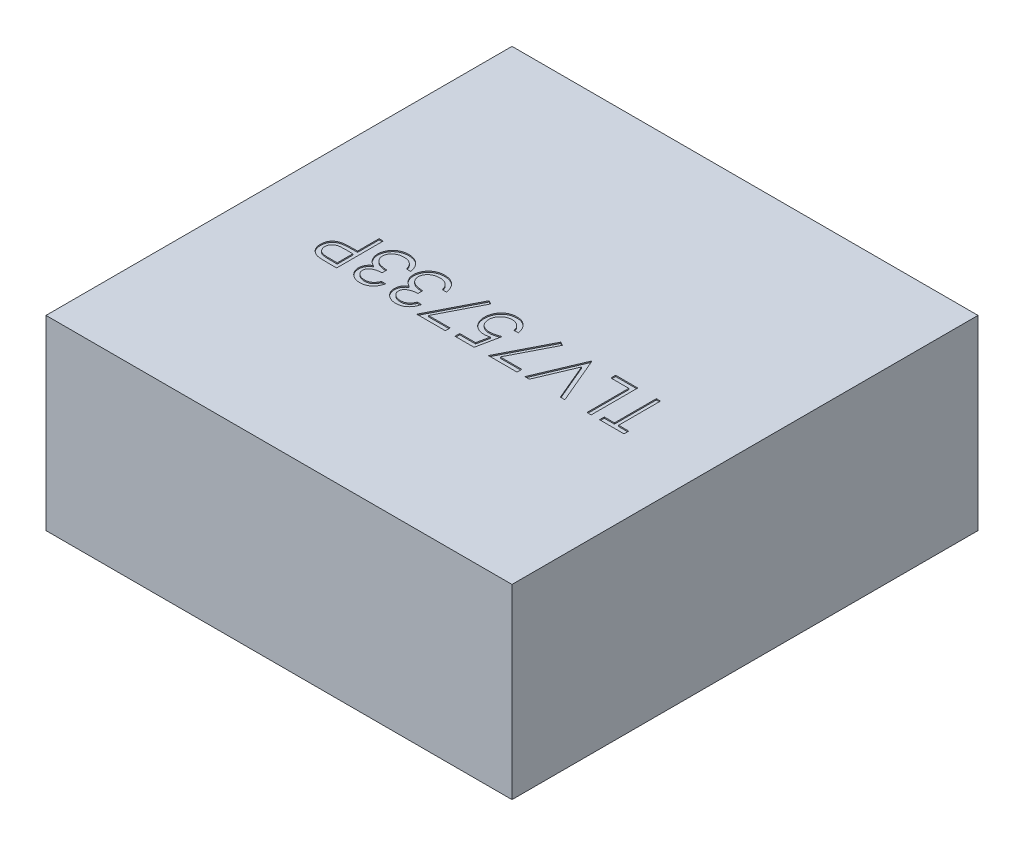
from build123d import *

# Parameters (mm, degrees)
BASES_W          = 2
BASES_H          = 2
BASE_DEPTH       = 0.8
PARTNUMBER_DEPTH = 0.005


with BuildPart() as part:
    # BaseS → Base (new body)
    with BuildSketch(Plane(origin=(0, 0, 0), x_dir=(1, 0, 0), z_dir=(0, 1, 0))):
        Rectangle(BASES_W, BASES_H)
    extrude(amount=BASE_DEPTH)

    # PartNumberS → PartNumber (cut)
    with BuildSketch(Plane(origin=(0, 0.8, 0), x_dir=(1, 0, 0), z_dir=(0, 1, 0))):
        Polygon((0.680769231, -0.179487179), (0.680769231, -0.2), (0.575641026, -0.2), (0.575641026, -0.179487179), (0.619230769, -0.179487179), (0.619230769, 0), (0.637179487, 0), (0.637179487, -0.179487179), align=None)
        Polygon((0.53974359, -0.2), (0.521794872, -0.2), (0.521794872, -0.020512821), (0.444871795, -0.020512821), (0.444871795, 0), (0.53974359, 0), align=None)
        Polygon((0.426923077, -0.2), (0.407692308, -0.2), (0.341025641, -0.042387821), (0.274358974, -0.2), (0.255128205, -0.2), (0.33974359, 0), (0.342307692, 0), align=None)
        Polygon((0.221794872, -0.2), (0.098717949, -0.2), (0.203846154, 0.005128205), (0.219350962, -0.003405449), (0.129086538, -0.179487179), (0.221794872, -0.179487179), align=None)
        with BuildLine():
            Line((-0.044871795, -0.2), (-0.044871795, -0.179487179))
            Line((-0.044871795, -0.179487179), (0.023157051, -0.179487179))
            Line((0.023157051, -0.179487179), (0.033934295, -0.126883013))
            add(Edge.make_bspline(
                [(0.033934295, -0.126883013), (0.031816816, -0.1274676), (0.027714537, -0.128600145), (0.021659687, -0.129857617), (0.015911561, -0.130615643), (0.01218154, -0.130719146), (0.010376603, -0.130769231)],
                knots=[0, 0, 0, 0, 1.100273476, 2.13160584, 3.095893838, 4, 4, 4, 4], degree=3))
            add(Edge.make_bspline(
                [(0.010376603, -0.130769231), (0.008142844, -0.130722475), (0.003750716, -0.130630542), (-0.00266564, -0.129695799), (-0.00882109, -0.128340984), (-0.014627096, -0.126257022), (-0.020177264, -0.12369573), (-0.025396346, -0.120511598), (-0.030308859, -0.116749998), (-0.034904064, -0.112488094), (-0.039046803, -0.107742932), (-0.04266112, -0.102636713), (-0.045750495, -0.097226416), (-0.048214901, -0.091462275), (-0.050212995, -0.085398611), (-0.051534137, -0.078984544), (-0.052415598, -0.072273437), (-0.05251395, -0.067684575), (-0.052564103, -0.065344551)],
                knots=[0, 0, 0, 0, 1.052656913, 2.069786496, 3.052102726, 4.020122636, 4.972424848, 5.930457368, 6.896570172, 7.885826804, 8.881139003, 9.861434336, 10.831623367, 11.813212553, 12.812997731, 13.836986694, 14.897002833, 16, 16, 16, 16], degree=3))
            add(Edge.make_bspline(
                [(-0.052564103, -0.065344551), (-0.052526069, -0.063714718), (-0.052450516, -0.060477078), (-0.052067024, -0.05566872), (-0.051326252, -0.050962711), (-0.050342361, -0.046368373), (-0.049034062, -0.041878849), (-0.047486935, -0.037483546), (-0.045635127, -0.033189737), (-0.043521961, -0.029018787), (-0.041117733, -0.02505279), (-0.038551881, -0.021245534), (-0.035755993, -0.017707472), (-0.032779013, -0.014379465), (-0.029563779, -0.011357231), (-0.026189195, -0.008514697), (-0.022579797, -0.005972433), (-0.018799216, -0.00363428), (-0.014850105, -0.001540748), (-0.010692348, 0.000205622), (-0.006417238, 0.001736333), (-0.001986665, 0.002981114), (0.002590784, 0.003946885), (0.007330874, 0.004604561), (0.01220982, 0.005083078), (0.015516956, 0.00511306), (0.0171875, 0.005128205)],
                knots=[0, 0, 0, 0, 1.056281413, 2.098288097, 3.122646807, 4.141030392, 5.140675379, 6.150604744, 7.15845591, 8.168533554, 9.177684096, 10.161739049, 11.141561652, 12.097360316, 13.052218386, 13.998410789, 14.954052752, 15.909851415, 16.877523809, 17.846742625, 18.829312613, 19.818263486, 20.826374662, 21.858017533, 22.918014209, 24, 24, 24, 24], degree=3))
            add(Edge.make_bspline(
                [(0.0171875, 0.005128205), (0.019180257, 0.005088619), (0.023100771, 0.005010738), (0.028845563, 0.004199816), (0.034369338, 0.003030456), (0.039649185, 0.001298915), (0.044660275, -0.000971722), (0.049475299, -0.003652227), (0.054006118, -0.006887491), (0.058284876, -0.010561531), (0.062209915, -0.014636501), (0.065823355, -0.018968808), (0.068952141, -0.023654541), (0.071670748, -0.028615525), (0.073983404, -0.033864696), (0.075801821, -0.039414236), (0.077269041, -0.045237188), (0.077889824, -0.049245947), (0.078205128, -0.051282051)],
                knots=[0, 0, 0, 0, 1.04695683, 2.059763882, 3.044413726, 4.012427942, 4.974081556, 5.932886124, 6.904940154, 7.895678616, 8.893654631, 9.876199664, 10.857615262, 11.850515636, 12.847107701, 13.868396357, 14.917328757, 16, 16, 16, 16], degree=3))
            Line((0.078205128, -0.051282051), (0.06025641, -0.051282051))
            add(Edge.make_bspline(
                [(0.06025641, -0.051282051), (0.059815333, -0.049374443), (0.058967558, -0.045707913), (0.057096993, -0.040562644), (0.054846086, -0.03595852), (0.052045418, -0.031924495), (0.04886416, -0.028324783), (0.045192472, -0.025123656), (0.041061558, -0.022270508), (0.036470494, -0.019872837), (0.031614568, -0.017856105), (0.026561981, -0.016416181), (0.021384479, -0.015544733), (0.017898621, -0.015438189), (0.016145833, -0.015384615)],
                knots=[0, 0, 0, 0, 1.136370375, 2.184166959, 3.172867797, 4.104539607, 5.027679118, 5.956634301, 6.927059835, 7.936867459, 8.959641981, 9.976160943, 10.98235693, 12, 12, 12, 12], degree=3))
            add(Edge.make_bspline(
                [(0.016145833, -0.015384615), (0.014434067, -0.015431909), (0.011063586, -0.015525032), (0.006100853, -0.016230204), (0.001323524, -0.017344777), (-0.00327688, -0.01890623), (-0.007677755, -0.02097194), (-0.011872877, -0.023509547), (-0.01592201, -0.026455739), (-0.019718587, -0.029823128), (-0.023194943, -0.033536101), (-0.026266769, -0.037506128), (-0.028825438, -0.041741405), (-0.030981676, -0.046168435), (-0.032619006, -0.050835783), (-0.033787063, -0.055721564), (-0.034472952, -0.060837848), (-0.034567305, -0.064327523), (-0.034615385, -0.066105769)],
                knots=[0, 0, 0, 0, 1.027268864, 2.022700798, 3.002744649, 3.968653148, 4.933396556, 5.915045722, 6.907600446, 7.935526002, 8.956456544, 9.95700807, 10.942805781, 11.92166854, 12.907987664, 13.905483474, 14.932689774, 16, 16, 16, 16], degree=3))
            add(Edge.make_bspline(
                [(-0.034615385, -0.066105769), (-0.034584995, -0.067711261), (-0.034525727, -0.070842346), (-0.033824813, -0.075418974), (-0.032880736, -0.079787618), (-0.031391757, -0.08390746), (-0.029583182, -0.087821511), (-0.027226683, -0.091433059), (-0.024621421, -0.094918694), (-0.021501441, -0.098047976), (-0.018123222, -0.100960292), (-0.014379546, -0.103430346), (-0.010377398, -0.105531902), (-0.006107453, -0.107253498), (-0.00156497, -0.108624951), (0.003252642, -0.109572763), (0.00834644, -0.110139924), (0.011830763, -0.110216862), (0.013621795, -0.11025641)],
                knots=[0, 0, 0, 0, 1.045820996, 2.039596555, 3.013371638, 3.9552447, 4.890047302, 5.817684688, 6.761648481, 7.722253242, 8.692244539, 9.66551337, 10.63924952, 11.635311376, 12.662847378, 13.728455105, 14.832366986, 16, 16, 16, 16], degree=3))
            add(Edge.make_bspline(
                [(0.013621795, -0.11025641), (0.015185482, -0.11022436), (0.018386592, -0.110158749), (0.023308293, -0.109642401), (0.028457756, -0.108848049), (0.033854972, -0.107703134), (0.03948513, -0.106269622), (0.045357593, -0.104479345), (0.051472502, -0.102417172), (0.055588274, -0.10081768), (0.057692308, -0.1)],
                knots=[0, 0, 0, 0, 0.824638674, 1.688163388, 2.607705698, 3.571998603, 4.597075385, 5.671199175, 6.809488238, 8, 8, 8, 8], degree=3))
            Line((0.057692308, -0.1), (0.037179487, -0.2))
            Line((0.037179487, -0.2), (-0.044871795, -0.2))
        make_face()
        Polygon((-0.085897436, -0.2), (-0.208974359, -0.2), (-0.103846154, 0.005128205), (-0.088341346, -0.003405449), (-0.178605769, -0.179487179), (-0.085897436, -0.179487179), align=None)
        with BuildLine():
            Line((-0.252564103, -0.153846154), (-0.234615385, -0.153846154))
            add(Edge.make_bspline(
                [(-0.234615385, -0.153846154), (-0.235101645, -0.155859439), (-0.236052243, -0.159795246), (-0.238034962, -0.165418518), (-0.240194919, -0.170739862), (-0.242788582, -0.175659638), (-0.245617654, -0.180276718), (-0.248858952, -0.184486382), (-0.252362936, -0.188395694), (-0.256238648, -0.191865022), (-0.260303143, -0.195006607), (-0.264613693, -0.197685181), (-0.269083572, -0.199989419), (-0.273743751, -0.201887718), (-0.278608104, -0.203317748), (-0.283632654, -0.204355279), (-0.288830568, -0.205029057), (-0.292359002, -0.205094815), (-0.294150641, -0.205128205)],
                knots=[0, 0, 0, 0, 1.162005537, 2.271625781, 3.343758855, 4.383309926, 5.390229558, 6.379919256, 7.361854164, 8.333198761, 9.295911338, 10.242430842, 11.177959212, 12.116337295, 13.062827104, 14.020064771, 14.994644689, 16, 16, 16, 16], degree=3))
            add(Edge.make_bspline(
                [(-0.294150641, -0.205128205), (-0.296761083, -0.205049392), (-0.301925027, -0.204893485), (-0.309511487, -0.203469803), (-0.316827305, -0.201216938), (-0.323792405, -0.198104154), (-0.33026203, -0.194264879), (-0.336018383, -0.189695465), (-0.340983441, -0.184484076), (-0.345148834, -0.17872793), (-0.348410262, -0.172576186), (-0.350815198, -0.166244749), (-0.352279294, -0.159748636), (-0.35246904, -0.155362506), (-0.352564103, -0.153165064)],
                knots=[0, 0, 0, 0, 1.083050992, 2.142477498, 3.193116406, 4.255571735, 5.30263384, 6.308962982, 7.297363603, 8.282367274, 9.249857812, 10.179914175, 11.08814088, 12, 12, 12, 12], degree=3))
            add(Edge.make_bspline(
                [(-0.352564103, -0.153165064), (-0.352497612, -0.15105039), (-0.352367499, -0.146912301), (-0.351262716, -0.140871073), (-0.349403501, -0.135177267), (-0.346828086, -0.129806915), (-0.343494283, -0.124794067), (-0.339455843, -0.120127445), (-0.334684263, -0.11578635), (-0.331068323, -0.113299523), (-0.329206731, -0.112019231)],
                knots=[0, 0, 0, 0, 1.024540389, 2.004866551, 2.965041327, 3.920577974, 4.882998113, 5.874504559, 6.905732034, 8, 8, 8, 8], degree=3))
            add(Edge.make_bspline(
                [(-0.329206731, -0.112019231), (-0.331336971, -0.110995631), (-0.335564434, -0.108964297), (-0.341268516, -0.104917242), (-0.346525572, -0.100359254), (-0.349422874, -0.096762548), (-0.35088141, -0.094951923)],
                knots=[0, 0, 0, 0, 1.015663554, 2.015584519, 3.001021554, 4, 4, 4, 4], degree=3))
            add(Edge.make_bspline(
                [(-0.35088141, -0.094951923), (-0.351844164, -0.093634478), (-0.353753907, -0.091021161), (-0.3561045, -0.086817028), (-0.358261328, -0.082580215), (-0.35984869, -0.078144135), (-0.361218522, -0.073651284), (-0.362119825, -0.069005451), (-0.362698426, -0.064250776), (-0.362779673, -0.061032679), (-0.362820513, -0.059415064)],
                knots=[0, 0, 0, 0, 1.02516404, 2.033540309, 3.025129118, 4.011046665, 4.991655828, 5.976607087, 6.982917762, 8, 8, 8, 8], degree=3))
            add(Edge.make_bspline(
                [(-0.362820513, -0.059415064), (-0.362717729, -0.056614634), (-0.362512644, -0.051026954), (-0.360687448, -0.04276937), (-0.357840373, -0.034712452), (-0.353872501, -0.026970463), (-0.348941038, -0.019748905), (-0.343106446, -0.013268976), (-0.336362512, -0.007749819), (-0.328905592, -0.003097513), (-0.320795508, 0.000589387), (-0.312155603, 0.003246097), (-0.30303703, 0.00483975), (-0.29680125, 0.005030959), (-0.293629808, 0.005128205)],
                knots=[0, 0, 0, 0, 0.955619592, 1.906742024, 2.874954321, 3.868585453, 4.869520953, 5.854611167, 6.836527075, 7.836578462, 8.849204403, 9.870874567, 10.917152508, 12, 12, 12, 12], degree=3))
            add(Edge.make_bspline(
                [(-0.293629808, 0.005128205), (-0.291491697, 0.00507816), (-0.287284607, 0.004979689), (-0.281097347, 0.004318503), (-0.275203834, 0.003078069), (-0.269546838, 0.001518053), (-0.264211739, -0.000638844), (-0.259121794, -0.003210266), (-0.254299316, -0.006262151), (-0.249772943, -0.009799634), (-0.245547511, -0.013759317), (-0.241730671, -0.018206982), (-0.238280192, -0.023059619), (-0.235218, -0.02836088), (-0.232531206, -0.034095915), (-0.23027763, -0.040287707), (-0.228309979, -0.046888254), (-0.227393366, -0.051486777), (-0.226923077, -0.053846154)],
                knots=[0, 0, 0, 0, 1.048603596, 2.063302207, 3.045874044, 3.999447474, 4.937100059, 5.862643889, 6.7929026, 7.7308982, 8.676022965, 9.627908155, 10.600123445, 11.591992905, 12.626222643, 13.701663232, 14.820785756, 16, 16, 16, 16], degree=3))
            Line((-0.226923077, -0.053846154), (-0.244871795, -0.053846154))
            add(Edge.make_bspline(
                [(-0.244871795, -0.053846154), (-0.245339412, -0.05230621), (-0.246248967, -0.049310886), (-0.247797212, -0.045000012), (-0.249561113, -0.041048123), (-0.251453374, -0.03742623), (-0.253440714, -0.034098664), (-0.255664424, -0.031153415), (-0.257959803, -0.028461117), (-0.259690052, -0.026944282), (-0.260536859, -0.026201923)],
                knots=[0, 0, 0, 0, 1.198163088, 2.33053128, 3.407730985, 4.417276592, 5.372219308, 6.28897303, 7.162600585, 8, 8, 8, 8], degree=3))
            add(Edge.make_bspline(
                [(-0.260536859, -0.026201923), (-0.261656788, -0.025338946), (-0.26389319, -0.023615655), (-0.267535212, -0.021410219), (-0.271378905, -0.019522419), (-0.275456321, -0.017987935), (-0.27976801, -0.016836097), (-0.284296479, -0.016007058), (-0.28904916, -0.015459763), (-0.292292772, -0.01541003), (-0.293950321, -0.015384615)],
                knots=[0, 0, 0, 0, 0.946083416, 1.889246487, 2.84504177, 3.809995578, 4.801312957, 5.829064617, 6.89060985, 8, 8, 8, 8], degree=3))
            add(Edge.make_bspline(
                [(-0.293950321, -0.015384615), (-0.295821975, -0.015419753), (-0.299481833, -0.015488461), (-0.304821756, -0.016122158), (-0.309903447, -0.017041039), (-0.314675045, -0.018478347), (-0.319201481, -0.020202635), (-0.323381711, -0.022460045), (-0.32733863, -0.025009425), (-0.330956317, -0.027974844), (-0.334217839, -0.031180141), (-0.337036154, -0.034580675), (-0.339477138, -0.038071008), (-0.341439281, -0.041732562), (-0.342991429, -0.045529421), (-0.344047428, -0.049475795), (-0.344781849, -0.053538455), (-0.344841649, -0.056300116), (-0.344871795, -0.057692308)],
                knots=[0, 0, 0, 0, 1.216990249, 2.379719373, 3.493992396, 4.571561497, 5.616923107, 6.638958652, 7.655775068, 8.674704564, 9.676001865, 10.625896028, 11.54399481, 12.441854662, 13.322657739, 14.20572845, 15.095482574, 16, 16, 16, 16], degree=3))
            add(Edge.make_bspline(
                [(-0.344871795, -0.057692308), (-0.344784167, -0.059555696), (-0.344609346, -0.0632732), (-0.34328016, -0.068744529), (-0.341074286, -0.074018171), (-0.338046202, -0.079025064), (-0.334271747, -0.083611196), (-0.32992934, -0.08771628), (-0.324926328, -0.091134393), (-0.32029549, -0.093489428), (-0.316182981, -0.095058495), (-0.31267069, -0.096158774), (-0.308735058, -0.097038296), (-0.304423376, -0.097889066), (-0.299717445, -0.098602295), (-0.29461303, -0.099199653), (-0.289108075, -0.099676883), (-0.285297159, -0.099890117), (-0.283333333, -0.1)],
                knots=[0, 0, 0, 0, 1.070440979, 2.135555593, 3.216243406, 4.345886539, 5.486149072, 6.621334998, 7.769144672, 8.957074012, 9.598644492, 10.297969361, 11.070758978, 11.915404831, 12.824182859, 13.805940418, 14.869366021, 16, 16, 16, 16], degree=3))
            Line((-0.283333333, -0.1), (-0.283333333, -0.120512821))
            add(Edge.make_bspline(
                [(-0.283333333, -0.120512821), (-0.285806723, -0.120561043), (-0.290649793, -0.120655467), (-0.297744165, -0.12156233), (-0.304507319, -0.123034295), (-0.310837527, -0.125089351), (-0.316577441, -0.127591218), (-0.321604791, -0.130392354), (-0.325738717, -0.133623909), (-0.329053258, -0.137133123), (-0.33151169, -0.140920736), (-0.333326358, -0.144850479), (-0.334399697, -0.148995461), (-0.334543235, -0.151823627), (-0.334615385, -0.153245192)],
                knots=[0, 0, 0, 0, 1.321816535, 2.58820849, 3.816448615, 5.017641336, 6.139869627, 7.160068286, 8.085608132, 8.934319198, 9.728416342, 10.48890201, 11.240453369, 12, 12, 12, 12], degree=3))
            add(Edge.make_bspline(
                [(-0.334615385, -0.153245192), (-0.334592225, -0.154289811), (-0.33454615, -0.156368031), (-0.333941878, -0.159413745), (-0.333075802, -0.162366392), (-0.331817567, -0.165191473), (-0.330190288, -0.167897968), (-0.328221523, -0.170495763), (-0.325906283, -0.173009663), (-0.323259606, -0.175384225), (-0.320305845, -0.177521373), (-0.317163555, -0.179426611), (-0.313820484, -0.181028645), (-0.310298418, -0.182356622), (-0.30657832, -0.183353822), (-0.302679758, -0.184070288), (-0.29859472, -0.184518117), (-0.295807768, -0.184582603), (-0.294391026, -0.184615385)],
                knots=[0, 0, 0, 0, 0.884246871, 1.759167212, 2.622361933, 3.489113179, 4.372562419, 5.294145153, 6.247651513, 7.265905295, 8.30305477, 9.334068495, 10.37719476, 11.441246459, 12.52060732, 13.637552802, 14.799054011, 16, 16, 16, 16], degree=3))
            add(Edge.make_bspline(
                [(-0.294391026, -0.184615385), (-0.292113712, -0.184536032), (-0.287665589, -0.184381039), (-0.281254357, -0.183018718), (-0.275300401, -0.180860261), (-0.270764688, -0.178253931), (-0.267409674, -0.17569), (-0.264966247, -0.17348425), (-0.262610533, -0.170983381), (-0.260434973, -0.168118798), (-0.258309201, -0.164989002), (-0.256253517, -0.161576754), (-0.254333949, -0.157833407), (-0.253165476, -0.155200978), (-0.252564103, -0.153846154)],
                knots=[0, 0, 0, 0, 1.4727372, 2.876598283, 4.222346151, 5.558423782, 6.24313385, 6.953189256, 7.68715613, 8.463578749, 9.278833271, 10.135787152, 11.040551781, 12, 12, 12, 12], degree=3))
        make_face()
        with BuildLine():
            Line((-0.406410256, -0.153846154), (-0.388461538, -0.153846154))
            add(Edge.make_bspline(
                [(-0.388461538, -0.153846154), (-0.388947799, -0.155859439), (-0.389898397, -0.159795246), (-0.391881116, -0.165418518), (-0.394041073, -0.170739862), (-0.396634736, -0.175659638), (-0.399463808, -0.180276718), (-0.402705106, -0.184486382), (-0.40620909, -0.188395694), (-0.410084802, -0.191865022), (-0.414149297, -0.195006607), (-0.418459846, -0.197685181), (-0.422929726, -0.199989419), (-0.427589905, -0.201887718), (-0.432454258, -0.203317748), (-0.437478808, -0.204355279), (-0.442676722, -0.205029057), (-0.446205156, -0.205094815), (-0.447996795, -0.205128205)],
                knots=[0, 0, 0, 0, 1.162005537, 2.271625781, 3.343758855, 4.383309926, 5.390229558, 6.379919256, 7.361854164, 8.333198761, 9.295911338, 10.242430842, 11.177959212, 12.116337295, 13.062827104, 14.020064771, 14.994644689, 16, 16, 16, 16], degree=3))
            add(Edge.make_bspline(
                [(-0.447996795, -0.205128205), (-0.450607237, -0.205049392), (-0.455771181, -0.204893485), (-0.463357641, -0.203469803), (-0.470673459, -0.201216938), (-0.477638559, -0.198104154), (-0.484108183, -0.194264879), (-0.489864537, -0.189695465), (-0.494829595, -0.184484076), (-0.498994988, -0.17872793), (-0.502256416, -0.172576186), (-0.504661352, -0.166244749), (-0.506125448, -0.159748636), (-0.506315194, -0.155362506), (-0.506410256, -0.153165064)],
                knots=[0, 0, 0, 0, 1.083050992, 2.142477498, 3.193116406, 4.255571735, 5.30263384, 6.308962982, 7.297363603, 8.282367274, 9.249857812, 10.179914175, 11.08814088, 12, 12, 12, 12], degree=3))
            add(Edge.make_bspline(
                [(-0.506410256, -0.153165064), (-0.506343765, -0.15105039), (-0.506213653, -0.146912301), (-0.50510887, -0.140871073), (-0.503249655, -0.135177267), (-0.50067424, -0.129806915), (-0.497340437, -0.124794067), (-0.493301997, -0.120127445), (-0.488530417, -0.11578635), (-0.484914477, -0.113299523), (-0.483052885, -0.112019231)],
                knots=[0, 0, 0, 0, 1.024540389, 2.004866551, 2.965041327, 3.920577974, 4.882998113, 5.874504559, 6.905732034, 8, 8, 8, 8], degree=3))
            add(Edge.make_bspline(
                [(-0.483052885, -0.112019231), (-0.485183125, -0.110995631), (-0.489410588, -0.108964297), (-0.49511467, -0.104917242), (-0.500371726, -0.100359254), (-0.503269028, -0.096762548), (-0.504727564, -0.094951923)],
                knots=[0, 0, 0, 0, 1.015663554, 2.015584519, 3.001021554, 4, 4, 4, 4], degree=3))
            add(Edge.make_bspline(
                [(-0.504727564, -0.094951923), (-0.505690318, -0.093634478), (-0.507600061, -0.091021161), (-0.509950654, -0.086817028), (-0.512107482, -0.082580215), (-0.513694844, -0.078144135), (-0.515064675, -0.073651284), (-0.515965979, -0.069005451), (-0.516544579, -0.064250776), (-0.516625827, -0.061032679), (-0.516666667, -0.059415064)],
                knots=[0, 0, 0, 0, 1.02516404, 2.033540309, 3.025129118, 4.011046665, 4.991655828, 5.976607087, 6.982917762, 8, 8, 8, 8], degree=3))
            add(Edge.make_bspline(
                [(-0.516666667, -0.059415064), (-0.516563882, -0.056614634), (-0.516358798, -0.051026954), (-0.514533602, -0.04276937), (-0.511686526, -0.034712452), (-0.507718655, -0.026970463), (-0.502787192, -0.019748905), (-0.496952599, -0.013268976), (-0.490208666, -0.007749819), (-0.482751746, -0.003097513), (-0.474641662, 0.000589387), (-0.466001757, 0.003246097), (-0.456883184, 0.00483975), (-0.450647404, 0.005030959), (-0.447475962, 0.005128205)],
                knots=[0, 0, 0, 0, 0.955619592, 1.906742024, 2.874954321, 3.868585453, 4.869520953, 5.854611167, 6.836527075, 7.836578462, 8.849204403, 9.870874567, 10.917152508, 12, 12, 12, 12], degree=3))
            add(Edge.make_bspline(
                [(-0.447475962, 0.005128205), (-0.44533785, 0.00507816), (-0.441130761, 0.004979689), (-0.434943501, 0.004318503), (-0.429049988, 0.003078069), (-0.423392992, 0.001518053), (-0.418057892, -0.000638844), (-0.412967948, -0.003210266), (-0.40814547, -0.006262151), (-0.403619097, -0.009799634), (-0.399393665, -0.013759317), (-0.395576825, -0.018206982), (-0.392126346, -0.023059619), (-0.389064154, -0.02836088), (-0.386377359, -0.034095915), (-0.384123783, -0.040287707), (-0.382156133, -0.046888254), (-0.38123952, -0.051486777), (-0.380769231, -0.053846154)],
                knots=[0, 0, 0, 0, 1.048603596, 2.063302207, 3.045874044, 3.999447474, 4.937100059, 5.862643889, 6.7929026, 7.7308982, 8.676022965, 9.627908155, 10.600123445, 11.591992905, 12.626222643, 13.701663232, 14.820785756, 16, 16, 16, 16], degree=3))
            Line((-0.380769231, -0.053846154), (-0.398717949, -0.053846154))
            add(Edge.make_bspline(
                [(-0.398717949, -0.053846154), (-0.399185565, -0.05230621), (-0.40009512, -0.049310886), (-0.401643366, -0.045000012), (-0.403407267, -0.041048123), (-0.405299528, -0.03742623), (-0.407286868, -0.034098664), (-0.409510578, -0.031153415), (-0.411805957, -0.028461117), (-0.413536206, -0.026944282), (-0.414383013, -0.026201923)],
                knots=[0, 0, 0, 0, 1.198163088, 2.33053128, 3.407730985, 4.417276592, 5.372219308, 6.28897303, 7.162600585, 8, 8, 8, 8], degree=3))
            add(Edge.make_bspline(
                [(-0.414383013, -0.026201923), (-0.415502942, -0.025338946), (-0.417739344, -0.023615655), (-0.421381366, -0.021410219), (-0.425225058, -0.019522419), (-0.429302475, -0.017987935), (-0.433614163, -0.016836097), (-0.438142633, -0.016007058), (-0.442895314, -0.015459763), (-0.446138926, -0.01541003), (-0.447796474, -0.015384615)],
                knots=[0, 0, 0, 0, 0.946083416, 1.889246487, 2.84504177, 3.809995578, 4.801312957, 5.829064617, 6.89060985, 8, 8, 8, 8], degree=3))
            add(Edge.make_bspline(
                [(-0.447796474, -0.015384615), (-0.449668128, -0.015419753), (-0.453327986, -0.015488461), (-0.45866791, -0.016122158), (-0.4637496, -0.017041039), (-0.468521199, -0.018478347), (-0.473047634, -0.020202635), (-0.477227865, -0.022460045), (-0.481184783, -0.025009425), (-0.484802471, -0.027974844), (-0.488063993, -0.031180141), (-0.490882308, -0.034580675), (-0.493323292, -0.038071008), (-0.495285435, -0.041732562), (-0.496837582, -0.045529421), (-0.497893582, -0.049475795), (-0.498628003, -0.053538455), (-0.498687803, -0.056300116), (-0.498717949, -0.057692308)],
                knots=[0, 0, 0, 0, 1.216990249, 2.379719373, 3.493992396, 4.571561497, 5.616923107, 6.638958652, 7.655775068, 8.674704564, 9.676001865, 10.625896028, 11.54399481, 12.441854662, 13.322657739, 14.20572845, 15.095482574, 16, 16, 16, 16], degree=3))
            add(Edge.make_bspline(
                [(-0.498717949, -0.057692308), (-0.49863032, -0.059555696), (-0.4984555, -0.0632732), (-0.497126314, -0.068744529), (-0.49492044, -0.074018171), (-0.491892356, -0.079025064), (-0.488117901, -0.083611196), (-0.483775494, -0.08771628), (-0.478772482, -0.091134393), (-0.474141643, -0.093489428), (-0.470029135, -0.095058495), (-0.466516843, -0.096158774), (-0.462581212, -0.097038296), (-0.458269529, -0.097889066), (-0.453563599, -0.098602295), (-0.448459183, -0.099199653), (-0.442954229, -0.099676883), (-0.439143313, -0.099890117), (-0.437179487, -0.1)],
                knots=[0, 0, 0, 0, 1.070440979, 2.135555593, 3.216243406, 4.345886539, 5.486149072, 6.621334998, 7.769144672, 8.957074012, 9.598644492, 10.297969361, 11.070758978, 11.915404831, 12.824182859, 13.805940418, 14.869366021, 16, 16, 16, 16], degree=3))
            Line((-0.437179487, -0.1), (-0.437179487, -0.120512821))
            add(Edge.make_bspline(
                [(-0.437179487, -0.120512821), (-0.439652877, -0.120561043), (-0.444495946, -0.120655467), (-0.451590319, -0.12156233), (-0.458353473, -0.123034295), (-0.464683681, -0.125089351), (-0.470423595, -0.127591218), (-0.475450945, -0.130392354), (-0.479584871, -0.133623909), (-0.482899412, -0.137133123), (-0.485357843, -0.140920736), (-0.487172512, -0.144850479), (-0.48824585, -0.148995461), (-0.488389389, -0.151823627), (-0.488461538, -0.153245192)],
                knots=[0, 0, 0, 0, 1.321816535, 2.58820849, 3.816448615, 5.017641336, 6.139869627, 7.160068286, 8.085608132, 8.934319198, 9.728416342, 10.48890201, 11.240453369, 12, 12, 12, 12], degree=3))
            add(Edge.make_bspline(
                [(-0.488461538, -0.153245192), (-0.488438379, -0.154289811), (-0.488392304, -0.156368031), (-0.487788032, -0.159413745), (-0.486921955, -0.162366392), (-0.485663721, -0.165191473), (-0.484036442, -0.167897968), (-0.482067676, -0.170495763), (-0.479752437, -0.173009663), (-0.477105759, -0.175384225), (-0.474151999, -0.177521373), (-0.471009709, -0.179426611), (-0.467666638, -0.181028645), (-0.464144572, -0.182356622), (-0.460424474, -0.183353822), (-0.456525912, -0.184070288), (-0.452440874, -0.184518117), (-0.449653922, -0.184582603), (-0.448237179, -0.184615385)],
                knots=[0, 0, 0, 0, 0.884246871, 1.759167212, 2.622361933, 3.489113179, 4.372562419, 5.294145153, 6.247651513, 7.265905295, 8.30305477, 9.334068495, 10.37719476, 11.441246459, 12.52060732, 13.637552802, 14.799054011, 16, 16, 16, 16], degree=3))
            add(Edge.make_bspline(
                [(-0.448237179, -0.184615385), (-0.445959866, -0.184536032), (-0.441511743, -0.184381039), (-0.435100511, -0.183018718), (-0.429146555, -0.180860261), (-0.424610842, -0.178253931), (-0.421255828, -0.17569), (-0.418812401, -0.17348425), (-0.416456687, -0.170983381), (-0.414281126, -0.168118798), (-0.412155355, -0.164989002), (-0.410099671, -0.161576754), (-0.408180103, -0.157833407), (-0.40701163, -0.155200978), (-0.406410256, -0.153846154)],
                knots=[0, 0, 0, 0, 1.4727372, 2.876598283, 4.222346151, 5.558423782, 6.24313385, 6.953189256, 7.68715613, 8.463578749, 9.278833271, 10.135787152, 11.040551781, 12, 12, 12, 12], degree=3))
        make_face()
        with BuildLine():
            Line((-0.552564103, -0.2), (-0.591786859, -0.2))
            add(Edge.make_bspline(
                [(-0.591786859, -0.2), (-0.594484625, -0.199997035), (-0.599653665, -0.199991352), (-0.607065954, -0.199819081), (-0.613797938, -0.199588985), (-0.619835103, -0.199270019), (-0.625196023, -0.198893071), (-0.62985644, -0.198364383), (-0.633852986, -0.197812366), (-0.63624764, -0.197251143), (-0.637339744, -0.196995192)],
                knots=[0, 0, 0, 0, 1.415646017, 2.712440637, 3.8905458, 4.950247383, 5.884950622, 6.709939814, 7.411656543, 8, 8, 8, 8], degree=3))
            add(Edge.make_bspline(
                [(-0.637339744, -0.196995192), (-0.638722222, -0.196616784), (-0.641454604, -0.195868883), (-0.645391933, -0.194371122), (-0.649137396, -0.192594385), (-0.652706657, -0.190572427), (-0.656038573, -0.188209761), (-0.659237172, -0.185642753), (-0.662235375, -0.182767587), (-0.664987909, -0.179588048), (-0.667538251, -0.176208296), (-0.669673071, -0.17254215), (-0.6715582, -0.16871679), (-0.673027298, -0.164638818), (-0.674182066, -0.160362064), (-0.675023085, -0.155875395), (-0.675563625, -0.151188492), (-0.675614916, -0.14798496), (-0.675641026, -0.146354167)],
                knots=[0, 0, 0, 0, 0.999333726, 1.975119402, 2.933498163, 3.889020618, 4.832249799, 5.779334906, 6.747801194, 7.724875447, 8.710438469, 9.696133548, 10.679360639, 11.681339199, 12.714023775, 13.766351759, 14.862936069, 16, 16, 16, 16], degree=3))
            add(Edge.make_bspline(
                [(-0.675641026, -0.146354167), (-0.675616944, -0.144709722), (-0.675569827, -0.141492256), (-0.675004325, -0.136785239), (-0.6742426, -0.132287046), (-0.67307134, -0.128007648), (-0.671537301, -0.123972462), (-0.669737756, -0.12011982), (-0.667567268, -0.116515267), (-0.665073278, -0.113145717), (-0.662298901, -0.110008008), (-0.659255876, -0.107124877), (-0.655956488, -0.104513201), (-0.652411222, -0.102167124), (-0.648585517, -0.100141051), (-0.644537394, -0.098326348), (-0.640231667, -0.096802287), (-0.637252095, -0.096000569), (-0.635737179, -0.095592949)],
                knots=[0, 0, 0, 0, 1.121902311, 2.195077645, 3.232258892, 4.234102512, 5.217864754, 6.176164875, 7.132989551, 8.084763148, 9.034132444, 9.988522005, 10.94243251, 11.903244335, 12.886203696, 13.894208494, 14.929344452, 16, 16, 16, 16], degree=3))
            add(Edge.make_bspline(
                [(-0.635737179, -0.095592949), (-0.634484175, -0.095326691), (-0.631738142, -0.094743172), (-0.627215984, -0.094087314), (-0.621948177, -0.093549438), (-0.615952644, -0.093047488), (-0.609215404, -0.092781517), (-0.601751909, -0.092469224), (-0.593536899, -0.09232187), (-0.587807186, -0.092312555), (-0.584815705, -0.092307692)],
                knots=[0, 0, 0, 0, 0.601372724, 1.317943291, 2.144091499, 3.08771165, 4.142394186, 5.309582461, 6.595334295, 8, 8, 8, 8], degree=3))
            Line((-0.584815705, -0.092307692), (-0.570512821, -0.092307692))
            Line((-0.570512821, -0.092307692), (-0.570512821, 0))
            Line((-0.570512821, 0), (-0.552564103, 0))
            Line((-0.552564103, 0), (-0.552564103, -0.2))
        make_face()
        with BuildLine():
            Line((-0.570512821, -0.179487179), (-0.570512821, -0.112820513))
            Line((-0.570512821, -0.112820513), (-0.605528846, -0.112379808))
            add(Edge.make_bspline(
                [(-0.605528846, -0.112379808), (-0.607238585, -0.11237868), (-0.610539201, -0.112376504), (-0.615319915, -0.112608136), (-0.619744637, -0.112860126), (-0.623819899, -0.113267653), (-0.627527101, -0.113764708), (-0.630875218, -0.114429274), (-0.633890971, -0.115107089), (-0.637364784, -0.116283217), (-0.641255819, -0.118057557), (-0.64547897, -0.120707753), (-0.649087306, -0.124046335), (-0.652183432, -0.127840667), (-0.654630707, -0.132066148), (-0.656404354, -0.136574615), (-0.657486952, -0.141348947), (-0.657623025, -0.144612418), (-0.657692308, -0.146274038)],
                knots=[0, 0, 0, 0, 1.160501667, 2.240324542, 3.248665471, 4.168823117, 5.020172044, 5.786515869, 6.485785279, 7.116517804, 8.272762037, 9.381837012, 10.485674779, 11.594342068, 12.695271952, 13.786226926, 14.872841088, 16, 16, 16, 16], degree=3))
            add(Edge.make_bspline(
                [(-0.657692308, -0.146274038), (-0.657619934, -0.147881827), (-0.657476064, -0.151077912), (-0.656413297, -0.155764279), (-0.654611924, -0.160221491), (-0.652181436, -0.164413482), (-0.649159505, -0.168197729), (-0.645622931, -0.171461906), (-0.641626739, -0.174103874), (-0.637938419, -0.175862608), (-0.634637664, -0.176893968), (-0.631784461, -0.177638558), (-0.628546512, -0.178152086), (-0.624954461, -0.178643436), (-0.621012906, -0.179040062), (-0.616696783, -0.179315492), (-0.61202047, -0.179474996), (-0.608774167, -0.17948302), (-0.607091346, -0.179487179)],
                knots=[0, 0, 0, 0, 1.12039168, 2.227199994, 3.330242575, 4.460839274, 5.593542475, 6.693949254, 7.801736126, 8.92216649, 9.528704869, 10.210659466, 10.975987387, 11.81211542, 12.738540127, 13.736887663, 14.826846554, 16, 16, 16, 16], degree=3))
            Line((-0.607091346, -0.179487179), (-0.570512821, -0.179487179))
        make_face(mode=Mode.SUBTRACT)
    extrude(amount=-PARTNUMBER_DEPTH, mode=Mode.SUBTRACT)


solid = part.part
